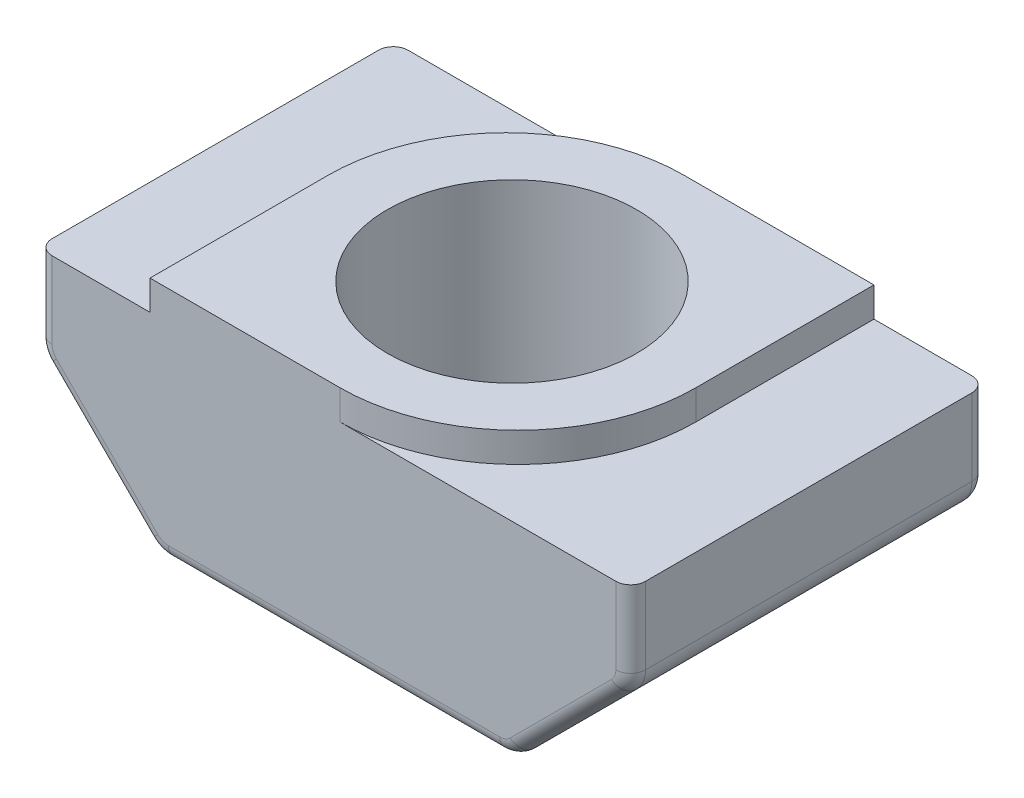
from build123d import *

# Parameters (mm, degrees)
BOSS_EXTRUDE1_DEPTH = 6
M5_TAPPED_HOLE1_D   = 4.2
FILLET1_R           = 3
FILLET2_R           = 0.5
FILLET3_R           = 0.25


with BuildPart() as part:
    # Sketch1 → Boss-Extrude1 (new body)
    with BuildSketch(Plane.XY):
        Polygon((3.1, 0), (-3.1, 0), (-3.1, -0.5), (-5, -0.5), (-5, -2), (-3, -4), (3, -4), (5, -2), (5, -0.5), (3.1, -0.5), align=None)
    extrude(amount=BOSS_EXTRUDE1_DEPTH)

    # M5 Tapped Hole1 (through all)
    with Locations(Plane(origin=(0, 0, 0), x_dir=(-1, 0, 0), z_dir=(0, 1, 0))):
        with Locations((0, 3)):
            Hole(M5_TAPPED_HOLE1_D / 2)

    # Fillet1
    fillet1_edges = [part.edges().sort_by_distance(p)[0] for p in [
        (-3.1, -0.25, 0),
        (3.1, -0.25, 6),
    ]]
    fillet(fillet1_edges, radius=FILLET1_R)

    # Fillet2
    fillet2_edges = [part.edges().sort_by_distance(p)[0] for p in [
        (5, -2, 3),
        (3, -4, 3),
        (-3, -4, 3),
        (-5, -2, 3),
    ]]
    fillet(fillet2_edges, radius=FILLET2_R)

    # Fillet3
    fillet3_edges = [part.edges().sort_by_distance(p)[0] for p in [
        (-5, -1.146446609, 6),
        (-5, -1.146446609, 0),
        (5, -1.146446609, 0),
        (5, -1.146446609, 6),
        (4, -3, 0),
        (0, -4, 0),
        (-4, -3, 0),
        (-2.984234935, -3.961939766, 0),
        (-4.961939766, -1.984234935, 0),
        (2.984234935, -3.961939766, 0),
        (4.961939766, -1.984234935, 0),
        (4, -3, 6),
        (-4, -3, 6),
        (0, -4, 6),
        (-2.984234935, -3.961939766, 6),
        (-4.961939766, -1.984234935, 6),
        (2.984234935, -3.961939766, 6),
        (4.961939766, -1.984234935, 6),
    ]]
    fillet(fillet3_edges, radius=FILLET3_R)


solid = part.part
